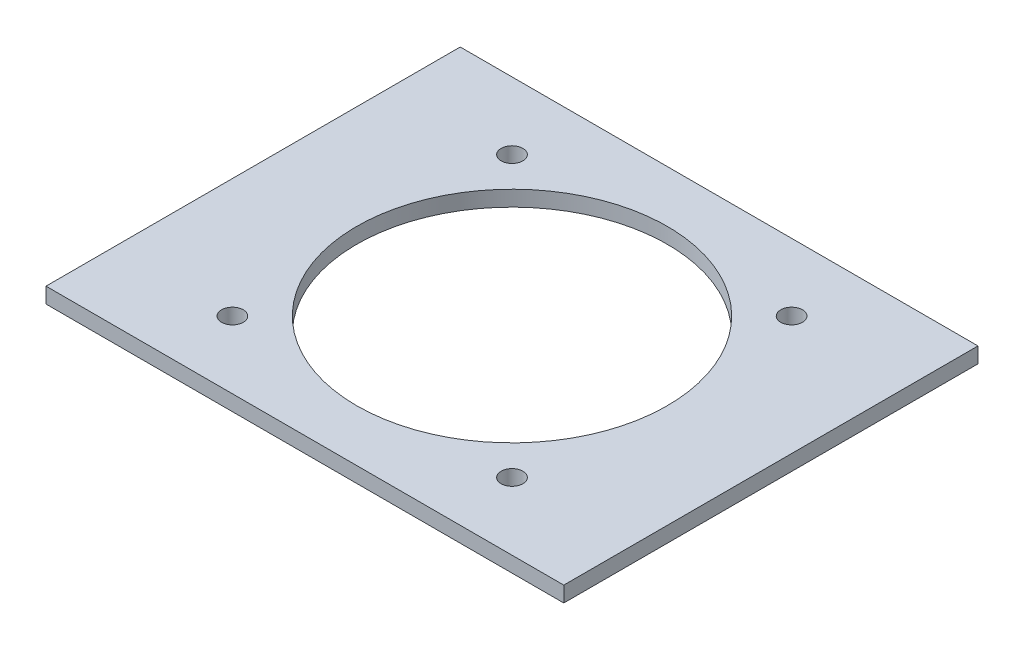
from build123d import *

# Parameters (mm, degrees)
SKETCH_1_W               = 100
SKETCH_1_H               = 80
SKETCH_1_R               = 30
EXTRUDE_1_DEPTH          = 3
SKETCH_2_R               = 2.1
CUT_EXTRUDE_1_DEPTH      = 10
PATTERN_CIRCULAR_1_COUNT = 4


with BuildPart() as part:
    # 草图1 → 凸台-拉伸1 (new body)
    with BuildSketch(Plane(origin=(0, 0, 0), x_dir=(1, 0, 0), z_dir=(0, 1, 0))):
        Rectangle(SKETCH_1_W, SKETCH_1_H)
        Circle(SKETCH_1_R, mode=Mode.SUBTRACT)
    extrude(amount=EXTRUDE_1_DEPTH)

    # 草图2 → 切除-拉伸1 (cut)
    with BuildSketch(Plane(origin=(0, 3, 0), x_dir=(1, 0, 0), z_dir=(0, 1, 0))):
        with Locations((27, 27)):
            Circle(SKETCH_2_R)
    cut_extrude_1 = extrude(amount=-CUT_EXTRUDE_1_DEPTH, mode=Mode.SUBTRACT)

    # 阵列(圆周)1: 切除-拉伸1 ×4 about axis
    pattern_circular_1_axis = Axis((0, 0, 0), (0, 1, 0))
    for i in range(1, PATTERN_CIRCULAR_1_COUNT):
        add(cut_extrude_1.rotate(pattern_circular_1_axis, i * 360 / PATTERN_CIRCULAR_1_COUNT), mode=Mode.SUBTRACT)


solid = part.part
